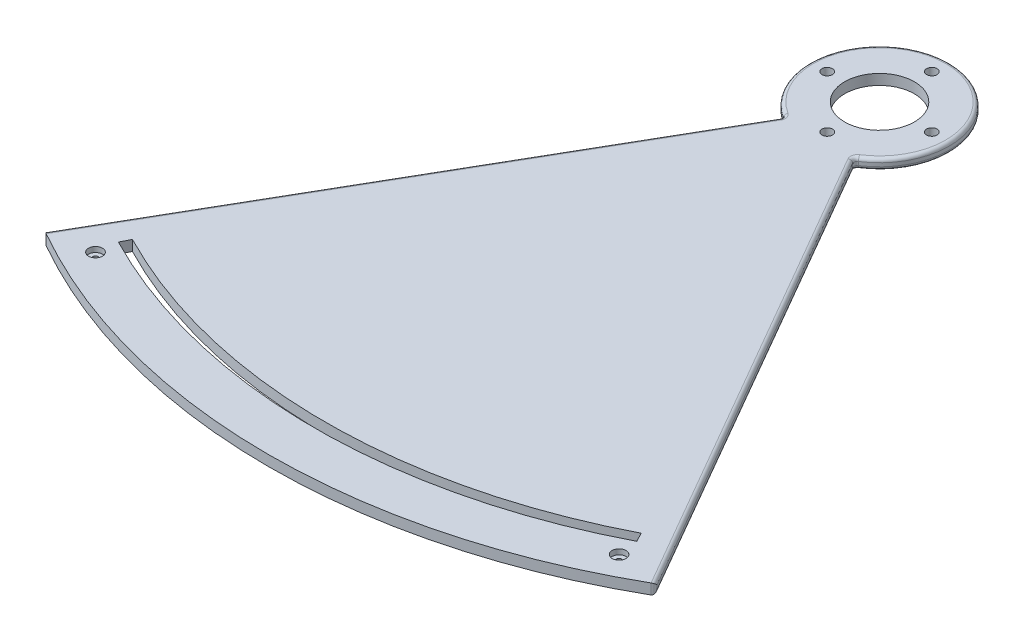
from build123d import *

# Parameters (mm, degrees)
SKETCH_1_R           = 10
SKETCH_1_R_2         = 1.5
EXTRUDE_1_DEPTH      = 3
SKETCH_1_6_W         = 90
SKETCH_1_6_H         = 60
CUT_EXTRUDE_8_DEPTH  = 1.2
SKETCH_1_7_W         = 60
SKETCH_1_7_H         = 90
CUT_EXTRUDE_10_DEPTH = 1.2
FILLET_1_R           = 1
CUT_EXTRUDE_20_DEPTH = 3
SKETCH_18_R          = 2
SKETCH_18_R_2        = 0.75
SKETCH_18_R_3        = 0.780733072
CUT_EXTRUDE_21_DEPTH = 1.5
SKETCH_18_2_R        = 0.780733072
SKETCH_18_2_R_2      = 0.75
CUT_EXTRUDE_22_DEPTH = 3


with BuildPart() as part:
    # Sketch 1 → Extrude 1 (new body)
    with BuildSketch(Plane(origin=(0, 0, 0), x_dir=(1, 0, 0), z_dir=(0, 1, 0))):
        with BuildLine():
            ThreePointArc((10, 92.846030188), (0, 130.166538264), (-10, 92.846030188))
            Line((-10, 92.846030188), (-87.624903698, -41.604246949))
            ThreePointArc((-87.624903698, -41.604246949), (0, -65.083269132), (87.624903698, -41.604246949))
            Line((87.624903698, -41.604246949), (10, 92.846030188))
        make_face()
        with Locations((0, 110.166538264)):
            Circle(SKETCH_1_R, mode=Mode.SUBTRACT)
        with Locations((-15, 110.166538264)):
            Circle(SKETCH_1_R_2, mode=Mode.SUBTRACT)
        with Locations((0, 95.166538264)):
            Circle(SKETCH_1_R_2, mode=Mode.SUBTRACT)
        with Locations((0, 125.166538264)):
            Circle(SKETCH_1_R_2, mode=Mode.SUBTRACT)
        with Locations((15, 110.166538264)):
            Circle(SKETCH_1_R_2, mode=Mode.SUBTRACT)
    extrude(amount=EXTRUDE_1_DEPTH)

    # Sketch 1_6 → Cut-Extrude 8 (cut)
    with BuildSketch(Plane(origin=(0, 0, 0), x_dir=(1, 0, 0), z_dir=(0, 1, 0))):
        Rectangle(SKETCH_1_6_W, SKETCH_1_6_H)
    extrude(amount=CUT_EXTRUDE_8_DEPTH, mode=Mode.SUBTRACT)

    # Sketch 1_7 → Cut-Extrude 10 (cut)
    with BuildSketch(Plane(origin=(0, 0, 0), x_dir=(1, 0, 0), z_dir=(0, 1, 0))):
        Rectangle(SKETCH_1_7_W, SKETCH_1_7_H)
    extrude(amount=CUT_EXTRUDE_10_DEPTH, mode=Mode.SUBTRACT)

    # Fillet 1
    fillet_1_edges = [part.edges().sort_by_distance(p)[0] for p in [
        (-48.812451849, 3, -25.620891619),
        (48.812451849, 0, -25.620891619),
        (-48.812451849, 0, -25.620891619),
        (0, 0, -130.166538264),
        (10, 1.5, -92.846030188),
        (-10, 1.5, -92.846030188),
        (48.812451849, 3, -25.620891619),
        (-87.624903698, 1.5, 41.604246949),
        (87.624903698, 1.5, 41.604246949),
        (0, 3, -130.166538264),
    ]]
    fillet(fillet_1_edges, radius=FILLET_1_R)

    # Sketch 12 → Cut-Extrude 20 (cut)
    with BuildSketch(Plane(origin=(0, 0, 0), x_dir=(1, 0, 0), z_dir=(0, 1, 0))):
        with BuildLine():
            Line((-72.960126375, -31.150674553), (-74.336385949, -33.816365755))
            ThreePointArc((-74.336385949, -33.816365755), (0.005384614, -51.873502765), (74.345954929, -33.81142502))
            Line((74.345954929, -33.81142502), (72.969518197, -31.14582529))
            ThreePointArc((72.969518197, -31.14582529), (0.005284923, -48.873502767), (-72.960126375, -31.150674553))
        make_face()
    extrude(amount=CUT_EXTRUDE_20_DEPTH, mode=Mode.SUBTRACT)

    # Sketch 18 → Cut-Extrude 21 (cut)
    with BuildSketch(Plane(origin=(0, 3, 0), x_dir=(1, 0, 0), z_dir=(0, 1, 0))):
        with Locations((75.092355786, -39.615982347)):
            Circle(SKETCH_18_R)
        with Locations((75.092355786, -39.615982347)):
            Circle(SKETCH_18_R_2, mode=Mode.SUBTRACT)
        with Locations((-75.092355786, -39.615982347)):
            Circle(SKETCH_18_R)
        with Locations((-75.092355786, -39.615982347)):
            Circle(SKETCH_18_R_3, mode=Mode.SUBTRACT)
    extrude(amount=-CUT_EXTRUDE_21_DEPTH, mode=Mode.SUBTRACT)

    # Sketch 18_2 → Cut-Extrude 22 (cut)
    with BuildSketch(Plane(origin=(0, 3, 0), x_dir=(1, 0, 0), z_dir=(0, 1, 0))):
        with Locations((-75.092355786, -39.615982347)):
            Circle(SKETCH_18_2_R)
        with Locations((75.092355786, -39.615982347)):
            Circle(SKETCH_18_2_R_2)
    extrude(amount=-CUT_EXTRUDE_22_DEPTH, mode=Mode.SUBTRACT)


solid = part.part
